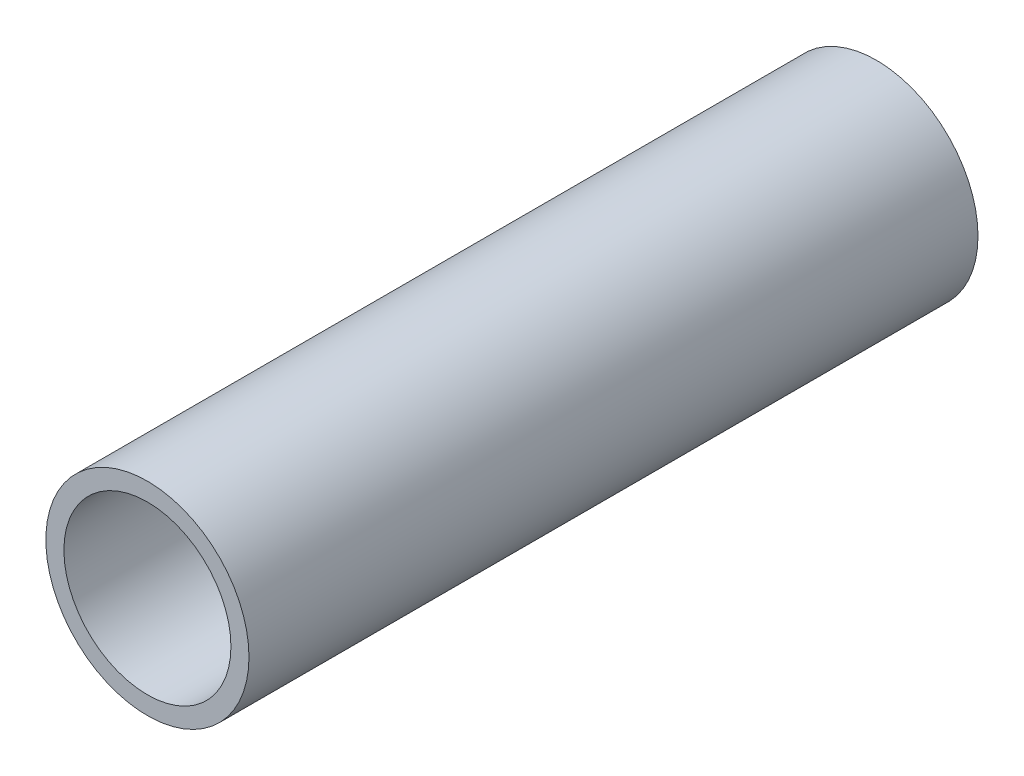
from build123d import *

# Parameters (mm, degrees)
SKETCH1_R           = 84.93125
SKETCH1_R_2         = 69.84365
BOSS_EXTRUDE1_DEPTH = 609.6


with BuildPart() as part:
    # Sketch1 → Boss-Extrude1 (new body)
    with BuildSketch(Plane.XY):
        Circle(SKETCH1_R)
        Circle(SKETCH1_R_2, mode=Mode.SUBTRACT)
    extrude(amount=BOSS_EXTRUDE1_DEPTH)


solid = part.part
